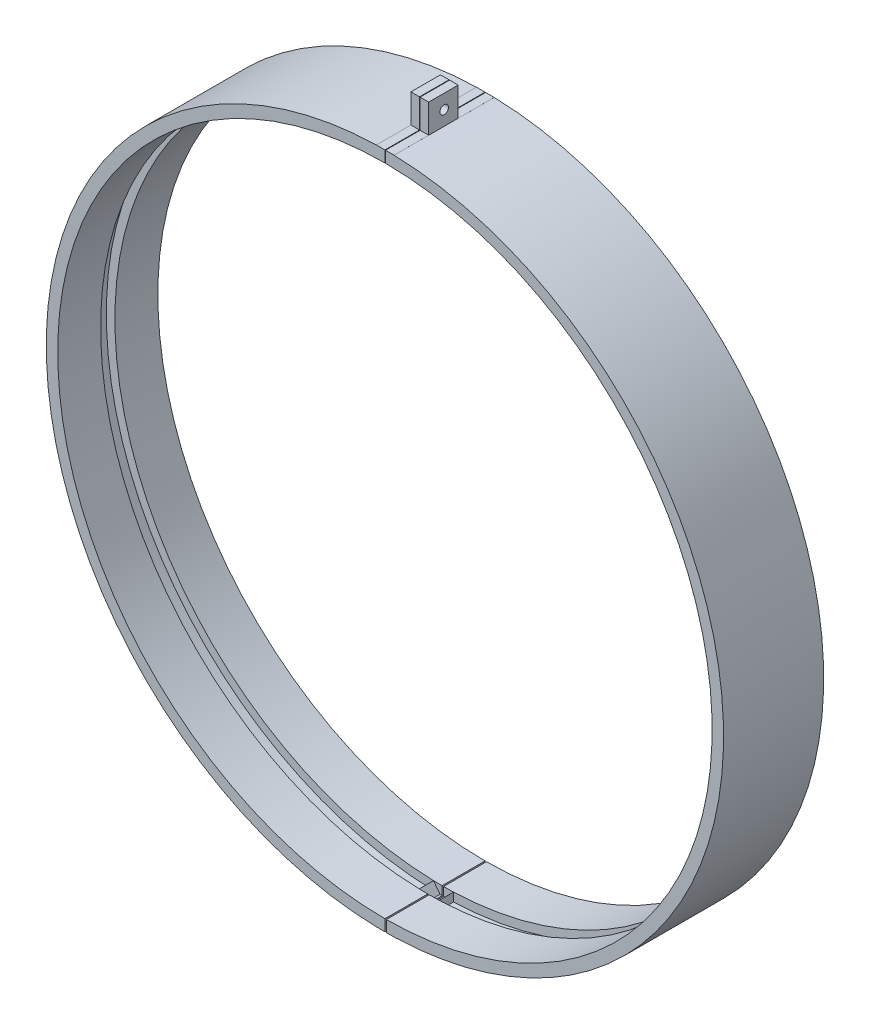
from build123d import *

# Parameters (mm, degrees)
SKETCH1_R      = 118.4
SKETCH1_R_2    = 114.4
EXTRUDE1_DEPTH = 15
SKETCH2_R      = 118.4
SKETCH2_R_2    = 117.4
EXTRUDE2_DEPTH = 5
SKETCH3_R      = 118.4
SKETCH3_R_2    = 114.4
EXTRUDE3_DEPTH = 15
EXTRUDE4_DEPTH = 35
SKETCH5_W      = 0.2
SKETCH5_H      = 17.636939157
SKETCH5_W_2    = 0.5
SKETCH5_H_2    = 21.284938381
EXTRUDE5_DEPTH = 36
SKETCH6_R      = 1.5
SKETCH6_W      = 12.085553783
SKETCH6_H      = 10.038012859
SKETCH6_W_2    = 12.582360216
EXTRUDE6_DEPTH = 122.4


with BuildPart() as part:
    # Sketch1 → Extrude1 (new body)
    with BuildSketch(Plane.XY):
        Circle(SKETCH1_R)
        Circle(SKETCH1_R_2, mode=Mode.SUBTRACT)
    extrude(amount=EXTRUDE1_DEPTH)

    # Sketch2 → Extrude2 (add)
    with BuildSketch(Plane.XY.offset(15)):
        Circle(SKETCH2_R)
        Circle(SKETCH2_R_2, mode=Mode.SUBTRACT)
    extrude(amount=EXTRUDE2_DEPTH)

    # Sketch3 → Extrude3 (add)
    with BuildSketch(Plane.XY.offset(20)):
        Circle(SKETCH3_R)
        Circle(SKETCH3_R_2, mode=Mode.SUBTRACT)
    extrude(amount=EXTRUDE3_DEPTH)

    # Sketch4 → Extrude4 (add)
    with BuildSketch(Plane.XY.offset(35)):
        with BuildLine():
            Line((0, 118.4), (0, 128.4))
            Line((0, 128.4), (-3, 128.4))
            Line((-3, 128.4), (-3, 114.360657571))
            ThreePointArc((-3, 114.360657571), (-2.167963765, 116.876422229), (0, 118.4))
        make_face()
        Polygon((0.2, 128.4), (3.2, 128.4), (3.2, 114.355235997), (0.2, 118.399831081), align=None)
        Polygon((0, -118.4), (0, -128.4), (-3, -128.4), (-3, -114.360657571), align=None)
        Polygon((0.5, -118.398944252), (0.5, -128.4), (4, -128.4), (4, -114.330048544), align=None)
    extrude(amount=-EXTRUDE4_DEPTH)

    # Sketch5 → Extrude5 (cut, through all)
    with BuildSketch(Plane.XY.offset(35)):
        with Locations((0.1, 119.581530422)):
            Rectangle(SKETCH5_W, SKETCH5_H)
        with Locations((0.25, -117.757530809)):
            Rectangle(SKETCH5_W_2, SKETCH5_H_2)
    extrude(amount=-EXTRUDE5_DEPTH, mode=Mode.SUBTRACT)

    # Sketch6 → Extrude6 (cut, through all)
    with BuildSketch(Plane.ZY.offset(3)):
        with Locations((17.5, 123.380993571)):
            Circle(SKETCH6_R)
        with Locations((17.5, -123.380993571)):
            Circle(SKETCH6_R)
        with Locations((28.957223109, 123.380993571)):
            Rectangle(SKETCH6_W, SKETCH6_H)
        with Locations((6.291180108, 123.380993571)):
            Rectangle(SKETCH6_W_2, SKETCH6_H)
        with Locations((28.957223109, -123.380993571)):
            Rectangle(SKETCH6_W, SKETCH6_H)
        with Locations((6.291180108, -123.380993571)):
            Rectangle(SKETCH6_W_2, SKETCH6_H)
    extrude(amount=-EXTRUDE6_DEPTH, mode=Mode.SUBTRACT)


solid = part.part
